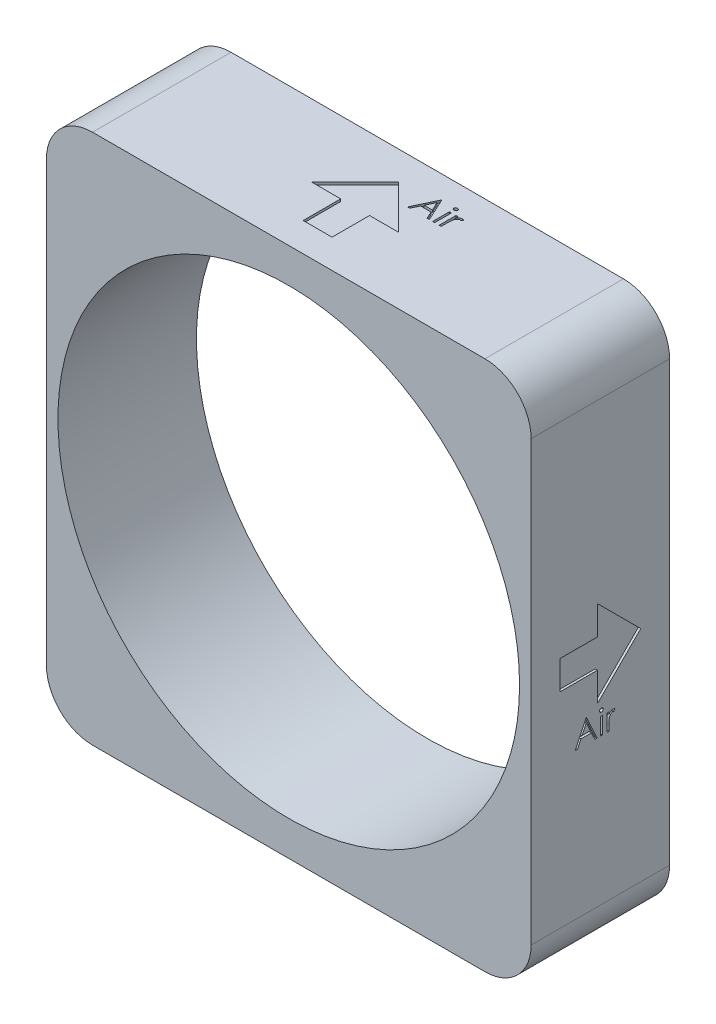
from build123d import *

# Parameters (mm, degrees)
SKETCH1_W           = 533.4
SKETCH1_H           = 584.2
BOSS_EXTRUDE1_DEPTH = 152.4
SKETCH2_R           = 254
CUT_EXTRUDE1_DEPTH  = 424.883309414
FILLET1_R           = 50.8
SKETCH3_W           = 2.279487179
SKETCH3_H           = 18.561538461
CUT_EXTRUDE2_DEPTH  = 2.54
SKETCH4_W           = 2.279487179
SKETCH4_H           = 18.561538462
CUT_EXTRUDE3_DEPTH  = 2.54
SKETCH7_W           = 2.279487179
SKETCH7_H           = 18.561538461
CUT_EXTRUDE4_DEPTH  = 2.54


with BuildPart() as part:
    # Sketch1 → Boss-Extrude1 (new body)
    with BuildSketch(Plane.XY):
        Rectangle(SKETCH1_W, SKETCH1_H)
    extrude(amount=BOSS_EXTRUDE1_DEPTH)

    # Sketch2 → Cut-Extrude1 (cut, through all)
    with BuildSketch(Plane.XY.offset(152.4)):
        Circle(SKETCH2_R)
    extrude(amount=-CUT_EXTRUDE1_DEPTH, mode=Mode.SUBTRACT)

    # Fillet1
    fillet1_edges = [part.edges().sort_by_distance(p)[0] for p in [
        (266.7, -292.1, 76.2),
        (-266.7, -292.1, 76.2),
        (-266.7, 292.1, 76.2),
        (266.7, 292.1, 76.2),
    ]]
    fillet(fillet1_edges, radius=FILLET1_R)

    # Sketch3 → Cut-Extrude2 (cut)
    with BuildSketch(Plane(origin=(266.7, 0, 0), x_dir=(0, 0, -1), z_dir=(1, 0, 0))):
        Polygon((-120.65, 15.875), (-120.65, -15.875), (-79.375, -15.875), (-79.375, -47.625), (-31.75, 0), (-79.375, 47.625), (-79.375, 15.875), align=None)
        Polygon((-91.466542944, -54.967447081), (-79.743466021, -80.367447081), (-82.2213907, -80.367447081), (-85.976438777, -72.22642144), (-97.490901918, -72.22642144), (-101.347712815, -80.367447081), (-103.840901918, -80.367447081), (-91.792183969, -54.967447081), align=None)
        Polygon((-91.654804162, -59.92329644), (-96.249395508, -69.621293235), (-87.177240059, -69.621293235), align=None, mode=Mode.SUBTRACT)
        with BuildLine():
            add(Edge.make_bspline(
                [(-75.031847431, -53.990524004), (-74.890396168, -53.997085567), (-74.613407427, -54.009934368), (-74.212861999, -54.119963373), (-73.848139683, -54.306469662), (-73.524632707, -54.556693632), (-73.247033301, -54.850966736), (-73.05268186, -55.193946334), (-72.927769042, -55.56448617), (-72.912684669, -55.82294996), (-72.905004482, -55.95454644)],
                knots=[0, 0, 0, 0, 1.055194115, 2.066272739, 3.074728998, 4.095836921, 5.109056067, 6.073838105, 7.019297344, 8, 8, 8, 8], degree=3))
            add(Edge.make_bspline(
                [(-72.905004482, -55.95454644), (-72.912857871, -56.082726838), (-72.92838309, -56.336124313), (-73.052585376, -56.700240368), (-73.248689617, -57.038454311), (-73.5244547, -57.332156036), (-73.848186851, -57.582241678), (-74.212849468, -57.768784641), (-74.613410723, -57.878803923), (-74.890397282, -57.891654064), (-75.031847431, -57.898216312)],
                knots=[0, 0, 0, 0, 0.96129708, 1.900370562, 2.859976407, 3.87933698, 4.906634145, 5.921202961, 6.938410037, 8, 8, 8, 8], degree=3))
            add(Edge.make_bspline(
                [(-75.031847431, -57.898216312), (-75.171680056, -57.891904628), (-75.443845992, -57.87961976), (-75.838393934, -57.766625917), (-76.2000064, -57.582177844), (-76.52414431, -57.333793529), (-76.79432914, -57.036650561), (-76.990985559, -56.700446771), (-77.114900996, -56.336071763), (-77.130464873, -56.082709185), (-77.138337815, -55.95454644)],
                knots=[0, 0, 0, 0, 1.054934014, 2.053291228, 3.073705704, 4.106921865, 5.123545215, 6.088680038, 7.033164197, 8, 8, 8, 8], degree=3))
            add(Edge.make_bspline(
                [(-77.138337815, -55.95454644), (-77.130637358, -55.822968275), (-77.115513175, -55.564540455), (-76.990892675, -55.193736502), (-76.795967212, -54.852785032), (-76.523965409, -54.555057122), (-76.200054011, -54.306533109), (-75.838381632, -54.122121986), (-75.443849242, -54.009118552), (-75.171681159, -53.996835008), (-75.031847431, -53.990524004)],
                knots=[0, 0, 0, 0, 0.98631895, 1.937192651, 2.907499808, 3.917963147, 4.944918757, 5.95915025, 6.951458133, 8, 8, 8, 8], degree=3))
        make_face()
        with Locations((-75.021671149, -71.086677851)):
            Rectangle(SKETCH3_W, SKETCH3_H)
        with BuildLine():
            Line((-68.997312174, -61.80590862), (-66.717824995, -61.80590862))
            Line((-66.717824995, -61.80590862), (-66.717824995, -64.538240351))
            add(Edge.make_bspline(
                [(-66.717824995, -64.538240351), (-66.54954086, -64.283835196), (-66.227698759, -63.797287316), (-65.692753501, -63.153801531), (-65.144815039, -62.62101805), (-64.581260252, -62.196449657), (-63.997944898, -61.878491595), (-63.40767102, -61.645587855), (-62.801151896, -61.507866767), (-62.393576788, -61.489479642), (-62.189379482, -61.480267594)],
                knots=[0, 0, 0, 0, 1.2804753, 2.448899062, 3.506932113, 4.484331642, 5.4025378, 6.288909075, 7.142734305, 8, 8, 8, 8], degree=3))
            add(Edge.make_bspline(
                [(-62.189379482, -61.480267594), (-62.030982713, -61.488907416), (-61.705071066, -61.50668441), (-61.2117117, -61.631585823), (-60.703396363, -61.830997758), (-60.37579161, -62.018523946), (-60.205004482, -62.116285222)],
                knots=[0, 0, 0, 0, 0.901110191, 1.854092781, 2.881294221, 4, 4, 4, 4], degree=3))
            Line((-60.205004482, -62.116285222), (-61.456687174, -64.09048394))
            add(Edge.make_bspline(
                [(-61.456687174, -64.09048394), (-61.566335499, -64.041568866), (-61.77446901, -63.948718692), (-62.078939291, -63.838830961), (-62.359655278, -63.774126886), (-62.538497101, -63.764324536), (-62.621871469, -63.759754774)],
                knots=[0, 0, 0, 0, 1.180555205, 2.24091978, 3.179933427, 4, 4, 4, 4], degree=3))
            add(Edge.make_bspline(
                [(-62.621871469, -63.759754774), (-62.804793078, -63.771947045), (-63.177900137, -63.796815744), (-63.725701932, -63.99231452), (-64.257267367, -64.308183406), (-64.679427431, -64.65849376), (-65.006305494, -64.996297776), (-65.239551702, -65.29128904), (-65.453512209, -65.622059681), (-65.657947523, -65.9829551), (-65.844211486, -66.380137411), (-66.018053943, -66.809638446), (-66.175235405, -67.271955666), (-66.264862892, -67.594045956), (-66.310773713, -67.75903362)],
                knots=[0, 0, 0, 0, 1.125678352, 2.296057538, 3.5422874, 4.923748041, 5.663163013, 6.437101912, 7.23742474, 8.08941207, 8.991984279, 9.93940061, 10.944477711, 12, 12, 12, 12], degree=3))
            add(Edge.make_bspline(
                [(-66.310773713, -67.75903362), (-66.345117368, -67.906187965), (-66.421185953, -68.232123658), (-66.495147399, -68.778938666), (-66.56822333, -69.424996075), (-66.619724503, -70.172094207), (-66.667462294, -71.018367371), (-66.694386891, -71.965104805), (-66.716906825, -73.013278268), (-66.717509653, -73.746063574), (-66.717824995, -74.129386184)],
                knots=[0, 0, 0, 0, 0.566838948, 1.255505196, 2.06880316, 3.007127437, 4.065329342, 5.249902469, 6.561414163, 8, 8, 8, 8], degree=3))
            Line((-66.717824995, -74.129386184), (-66.717824995, -80.367447081))
            Line((-66.717824995, -80.367447081), (-68.997312174, -80.367447081))
            Line((-68.997312174, -80.367447081), (-68.997312174, -61.80590862))
        make_face()
    extrude(amount=-CUT_EXTRUDE2_DEPTH, mode=Mode.SUBTRACT)

    # Sketch4 → Cut-Extrude3 (cut)
    with BuildSketch(Plane(origin=(0, 292.1, 0), x_dir=(1, 0, 0), z_dir=(0, 1, 0))):
        Polygon((-15.875, -120.65), (15.875, -120.65), (15.875, -79.375), (47.625, -79.375), (0, -31.75), (-47.625, -79.375), (-15.875, -79.375), align=None)
        Polygon((40.93696353, -24.952305098), (52.660040453, -50.352305098), (50.182115773, -50.352305098), (46.427067697, -42.211279457), (34.912604555, -42.211279457), (31.055793658, -50.352305098), (28.562604555, -50.352305098), (40.611322504, -24.952305098), align=None)
        Polygon((40.748702312, -29.908154457), (36.154110966, -39.606151252), (45.226266414, -39.606151252), align=None, mode=Mode.SUBTRACT)
        with BuildLine():
            add(Edge.make_bspline(
                [(57.371659043, -23.975382021), (57.513110306, -23.981943584), (57.790099046, -23.994792385), (58.190644475, -24.10482139), (58.555366791, -24.291327679), (58.878873767, -24.541551649), (59.156473173, -24.835824753), (59.350824614, -25.178804351), (59.475737431, -25.549344187), (59.490821804, -25.807807977), (59.498501991, -25.939404457)],
                knots=[0, 0, 0, 0, 1.055194115, 2.066272739, 3.074728998, 4.095836921, 5.109056067, 6.073838105, 7.019297344, 8, 8, 8, 8], degree=3))
            add(Edge.make_bspline(
                [(59.498501991, -25.939404457), (59.490648603, -26.067584854), (59.475123383, -26.32098233), (59.350921097, -26.685098384), (59.154816857, -27.023312327), (58.879051774, -27.317014053), (58.555319623, -27.567099695), (58.190657005, -27.753642657), (57.79009575, -27.86366194), (57.513109192, -27.876512081), (57.371659043, -27.883074329)],
                knots=[0, 0, 0, 0, 0.96129708, 1.900370562, 2.859976407, 3.87933698, 4.906634145, 5.921202961, 6.938410037, 8, 8, 8, 8], degree=3))
            add(Edge.make_bspline(
                [(57.371659043, -27.883074329), (57.231826417, -27.876762645), (56.959660481, -27.864477777), (56.56511254, -27.751483934), (56.203500074, -27.56703586), (55.879362164, -27.318651546), (55.609177333, -27.021508577), (55.412520915, -26.685304788), (55.288605477, -26.32092978), (55.273041601, -26.067567201), (55.265168658, -25.939404457)],
                knots=[0, 0, 0, 0, 1.054934014, 2.053291228, 3.073705704, 4.106921865, 5.123545215, 6.088680038, 7.033164197, 8, 8, 8, 8], degree=3))
            add(Edge.make_bspline(
                [(55.265168658, -25.939404457), (55.272869115, -25.807826291), (55.287993299, -25.549398472), (55.412613799, -25.178594519), (55.607539261, -24.837643048), (55.879541065, -24.539915138), (56.203452462, -24.291391126), (56.565124841, -24.106980003), (56.959657231, -23.993976569), (57.231825314, -23.981693025), (57.371659043, -23.975382021)],
                knots=[0, 0, 0, 0, 0.98631895, 1.937192651, 2.907499808, 3.917963147, 4.944918757, 5.95915025, 6.951458133, 8, 8, 8, 8], degree=3))
        make_face()
        with Locations((57.381835325, -41.071535867)):
            Rectangle(SKETCH4_W, SKETCH4_H)
        with BuildLine():
            Line((63.406194299, -31.790766636), (65.685681479, -31.790766636))
            Line((65.685681479, -31.790766636), (65.685681479, -34.523098367))
            add(Edge.make_bspline(
                [(65.685681479, -34.523098367), (65.853965614, -34.268693213), (66.175807714, -33.782145333), (66.710752973, -33.138659548), (67.258691434, -32.605876067), (67.822246222, -32.181307674), (68.405561576, -31.863349611), (68.995835454, -31.630445871), (69.602354578, -31.492724784), (70.009929685, -31.474337659), (70.214126991, -31.465125611)],
                knots=[0, 0, 0, 0, 1.2804753, 2.448899062, 3.506932113, 4.484331642, 5.4025378, 6.288909075, 7.142734305, 8, 8, 8, 8], degree=3))
            add(Edge.make_bspline(
                [(70.214126991, -31.465125611), (70.372523761, -31.473765432), (70.698435408, -31.491542427), (71.191794774, -31.61644384), (71.70011011, -31.815855775), (72.027714864, -32.003381962), (72.198501991, -32.101143239)],
                knots=[0, 0, 0, 0, 0.901110191, 1.854092781, 2.881294221, 4, 4, 4, 4], degree=3))
            Line((72.198501991, -32.101143239), (70.946819299, -34.075341957))
            add(Edge.make_bspline(
                [(70.946819299, -34.075341957), (70.837170974, -34.026426883), (70.629037463, -33.933576708), (70.324567182, -33.823688978), (70.043851196, -33.758984903), (69.865009372, -33.749182553), (69.781635004, -33.74461279)],
                knots=[0, 0, 0, 0, 1.180555205, 2.24091978, 3.179933427, 4, 4, 4, 4], degree=3))
            add(Edge.make_bspline(
                [(69.781635004, -33.74461279), (69.598713395, -33.756805062), (69.225606337, -33.781673761), (68.677804541, -33.977172537), (68.146239107, -34.293041422), (67.724079043, -34.643351777), (67.397200979, -34.981155793), (67.163954771, -35.276147057), (66.949994265, -35.606917697), (66.745558951, -35.967813117), (66.559294987, -36.364995428), (66.385452531, -36.794496463), (66.228271068, -37.256813683), (66.138643582, -37.578903973), (66.092732761, -37.743891636)],
                knots=[0, 0, 0, 0, 1.125678352, 2.296057538, 3.5422874, 4.923748041, 5.663163013, 6.437101912, 7.23742474, 8.08941207, 8.991984279, 9.93940061, 10.944477711, 12, 12, 12, 12], degree=3))
            add(Edge.make_bspline(
                [(66.092732761, -37.743891636), (66.058389106, -37.891045982), (65.98232052, -38.216981675), (65.908359074, -38.763796683), (65.835283144, -39.409854092), (65.783781971, -40.156952223), (65.736044179, -41.003225388), (65.709119583, -41.949962822), (65.686599648, -42.998136284), (65.68599682, -43.730921591), (65.685681479, -44.114244201)],
                knots=[0, 0, 0, 0, 0.566838948, 1.255505196, 2.06880316, 3.007127437, 4.065329342, 5.249902469, 6.561414163, 8, 8, 8, 8], degree=3))
            Line((65.685681479, -44.114244201), (65.685681479, -50.352305098))
            Line((65.685681479, -50.352305098), (63.406194299, -50.352305098))
            Line((63.406194299, -50.352305098), (63.406194299, -31.790766636))
        make_face()
    extrude(amount=-CUT_EXTRUDE3_DEPTH, mode=Mode.SUBTRACT)

    # Sketch7 → Cut-Extrude4 (cut)
    with BuildSketch(Plane.ZY.offset(266.7)):
        Polygon((120.65, -15.875), (120.65, 15.875), (79.375, 15.875), (79.375, 47.625), (31.75, 0), (79.375, -47.625), (79.375, -15.875), align=None)
        Polygon((65.69928562, -61.391172511), (77.422362543, -86.791172511), (74.944437863, -86.791172511), (71.189389786, -78.65014687), (59.674926645, -78.65014687), (55.818115748, -86.791172511), (53.324926645, -86.791172511), (65.373644594, -61.391172511), align=None)
        Polygon((65.511024402, -66.34702187), (60.916433056, -76.045018665), (69.988588504, -76.045018665), align=None, mode=Mode.SUBTRACT)
        with BuildLine():
            add(Edge.make_bspline(
                [(82.133981133, -60.414249434), (82.275432396, -60.420810997), (82.552421136, -60.433659798), (82.952966565, -60.543688803), (83.317688881, -60.730195092), (83.641195857, -60.980419062), (83.918795263, -61.274692166), (84.113146704, -61.617671764), (84.238059521, -61.9882116), (84.253143894, -62.24667539), (84.260824081, -62.37827187)],
                knots=[0, 0, 0, 0, 1.055194115, 2.066272739, 3.074728998, 4.095836921, 5.109056067, 6.073838105, 7.019297344, 8, 8, 8, 8], degree=3))
            add(Edge.make_bspline(
                [(84.260824081, -62.37827187), (84.252970693, -62.506452267), (84.237445473, -62.759849743), (84.113243187, -63.123965797), (83.917138947, -63.46217974), (83.641373864, -63.755881466), (83.317641712, -64.005967108), (82.952979095, -64.192510071), (82.55241784, -64.302529353), (82.275431281, -64.315379494), (82.133981133, -64.321941742)],
                knots=[0, 0, 0, 0, 0.96129708, 1.900370562, 2.859976407, 3.87933698, 4.906634145, 5.921202961, 6.938410037, 8, 8, 8, 8], degree=3))
            add(Edge.make_bspline(
                [(82.133981133, -64.321941742), (81.994148507, -64.315630058), (81.721982571, -64.30334519), (81.327434629, -64.190351347), (80.965822164, -64.005903274), (80.641684253, -63.757518959), (80.371499423, -63.46037599), (80.174843005, -63.124172201), (80.050927567, -62.759797193), (80.035363691, -62.506434615), (80.027490748, -62.37827187)],
                knots=[0, 0, 0, 0, 1.054934014, 2.053291228, 3.073705704, 4.106921865, 5.123545215, 6.088680038, 7.033164197, 8, 8, 8, 8], degree=3))
            add(Edge.make_bspline(
                [(80.027490748, -62.37827187), (80.035191205, -62.246693704), (80.050315389, -61.988265885), (80.174935889, -61.617461932), (80.369861351, -61.276510461), (80.641863155, -60.978782551), (80.965774552, -60.730258539), (81.327446931, -60.545847416), (81.721979321, -60.432843982), (81.994147404, -60.420560438), (82.133981133, -60.414249434)],
                knots=[0, 0, 0, 0, 0.98631895, 1.937192651, 2.907499808, 3.917963147, 4.944918757, 5.95915025, 6.951458133, 8, 8, 8, 8], degree=3))
        make_face()
        with Locations((82.144157415, -77.510403281)):
            Rectangle(SKETCH7_W, SKETCH7_H)
        with BuildLine():
            Line((88.168516389, -68.22963405), (90.448003568, -68.22963405))
            Line((90.448003568, -68.22963405), (90.448003568, -70.96196578))
            add(Edge.make_bspline(
                [(90.448003568, -70.96196578), (90.616287703, -70.707560626), (90.938129804, -70.221012746), (91.473075063, -69.577526961), (92.021013524, -69.04474348), (92.584568312, -68.620175087), (93.167883665, -68.302217024), (93.758157544, -68.069313285), (94.364676668, -67.931592197), (94.772251775, -67.913205072), (94.976449081, -67.903993024)],
                knots=[0, 0, 0, 0, 1.2804753, 2.448899062, 3.506932113, 4.484331642, 5.4025378, 6.288909075, 7.142734305, 8, 8, 8, 8], degree=3))
            add(Edge.make_bspline(
                [(94.976449081, -67.903993024), (95.134845851, -67.912632845), (95.460757498, -67.93040984), (95.954116864, -68.055311253), (96.4624322, -68.254723188), (96.790036953, -68.442249375), (96.960824081, -68.540010652)],
                knots=[0, 0, 0, 0, 0.901110191, 1.854092781, 2.881294221, 4, 4, 4, 4], degree=3))
            Line((96.960824081, -68.540010652), (95.709141389, -70.51420937))
            add(Edge.make_bspline(
                [(95.709141389, -70.51420937), (95.599493064, -70.465294296), (95.391359553, -70.372444121), (95.086889272, -70.262556391), (94.806173285, -70.197852316), (94.627331462, -70.188049966), (94.543957094, -70.183480203)],
                knots=[0, 0, 0, 0, 1.180555205, 2.24091978, 3.179933427, 4, 4, 4, 4], degree=3))
            add(Edge.make_bspline(
                [(94.543957094, -70.183480203), (94.361035485, -70.195672475), (93.987928427, -70.220541174), (93.440126631, -70.41603995), (92.908561197, -70.731908835), (92.486401133, -71.08221919), (92.159523069, -71.420023206), (91.926276861, -71.71501447), (91.712316355, -72.04578511), (91.507881041, -72.40668053), (91.321617077, -72.803862841), (91.147774621, -73.233363876), (90.990593158, -73.695681096), (90.900965672, -74.017771386), (90.855054851, -74.18275905)],
                knots=[0, 0, 0, 0, 1.125678352, 2.296057538, 3.5422874, 4.923748041, 5.663163013, 6.437101912, 7.23742474, 8.08941207, 8.991984279, 9.93940061, 10.944477711, 12, 12, 12, 12], degree=3))
            add(Edge.make_bspline(
                [(90.855054851, -74.18275905), (90.820711196, -74.329913395), (90.74464261, -74.655849088), (90.670681164, -75.202664096), (90.597605234, -75.848721505), (90.546104061, -76.595819636), (90.498366269, -77.442092801), (90.471441672, -78.388830235), (90.448921738, -79.437003697), (90.44831891, -80.169789004), (90.448003568, -80.553111614)],
                knots=[0, 0, 0, 0, 0.566838948, 1.255505196, 2.06880316, 3.007127437, 4.065329342, 5.249902469, 6.561414163, 8, 8, 8, 8], degree=3))
            Line((90.448003568, -80.553111614), (90.448003568, -86.791172511))
            Line((90.448003568, -86.791172511), (88.168516389, -86.791172511))
            Line((88.168516389, -86.791172511), (88.168516389, -68.22963405))
        make_face()
    extrude(amount=-CUT_EXTRUDE4_DEPTH, mode=Mode.SUBTRACT)


solid = part.part
